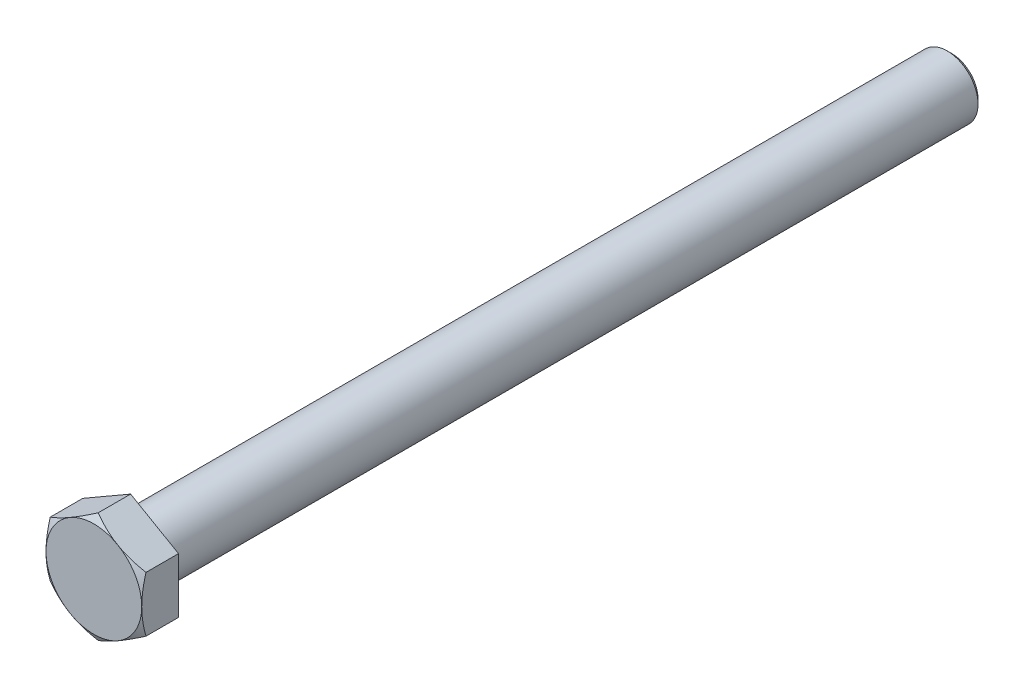
from build123d import *

# Parameters (mm, degrees)
BOSS_EXTRUDE1_DEPTH = 7.32


with BuildPart() as part:
    # Sketch1 → Boss-Extrude1 (new body)
    with BuildSketch(Plane.XY):
        Polygon((0, 10.779129526), (-9.335, 5.389564763), (-9.335, -5.389564763), (0, -10.779129526), (9.335, -5.389564763), (9.335, 5.389564763), align=None)
    extrude(amount=BOSS_EXTRUDE1_DEPTH)

    # Sketch2 → Revolve1 (revolve)
    with BuildSketch(Plane(origin=(0, 0, 0), x_dir=(0, 0, -1), z_dir=(1, 0, 0))):
        with BuildLine():
            Line((0, 0), (0, 6.6))
            ThreePointArc((0, 6.6), (0.175735931, 6.175735931), (0.6, 6))
            Line((0.6, 6), (159.1, 6))
            Line((159.1, 6), (160, 5.1))
            Line((160, 5.1), (160, 0))
            Line((160, 0), (0, 0))
        make_face()
    revolve(axis=Axis((0, 0, 0), (0, 0, -1)))

    # Sketch3 → Cut-Revolve1 (revolve, cut)
    with BuildSketch(Plane(origin=(0, 0, 0), x_dir=(0, 0, -1), z_dir=(1, 0, 0))):
        Polygon((-7.32, 10.779129526), (-6.48623143, 10.779129526), (-7.32, 9.335), align=None)
        Polygon((-0.15, 10.779129526), (-0.15, 8.78660254), (0, 8.7), (0, 10.779129526), align=None)
    revolve(axis=Axis((0, 0, 12.204941078), (0, 0, -1)), mode=Mode.SUBTRACT)


solid = part.part
